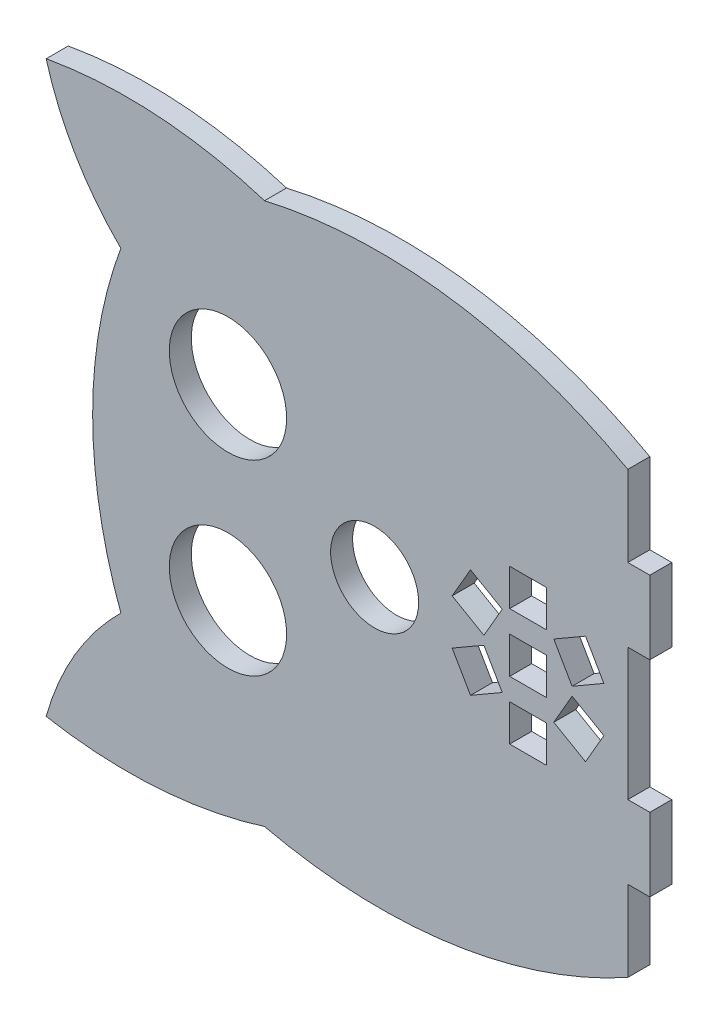
from build123d import *

# Parameters (mm, degrees)
SKETCH2_R           = 8
SKETCH2_R_2         = 6
SKETCH2_W           = 5
SKETCH2_H           = 5
BOSS_EXTRUDE1_DEPTH = 3


with BuildPart() as part:
    # Sketch2 → Boss-Extrude1 (new body)
    with BuildSketch(Plane.XY):
        with BuildLine():
            Line((81.032103119, 50.181312), (81.032103119, 60.181312))
            Line((81.032103119, 60.181312), (78.032103119, 60.181312))
            Line((78.032103119, 60.181312), (78.032103119, 71.181312))
            ThreePointArc((78.032103119, 71.181312), (53.908058205, 79.251221529), (28.494548306, 78.134755037))
            ThreePointArc((28.494548306, 78.134755037), (13.721692274, 80.8793749), (-1.279201176, 80.017163065))
            ThreePointArc((-1.279201176, 80.017163065), (2.677054283, 70.700200378), (8.902417187, 62.718809041))
            ThreePointArc((8.902417187, 62.718809041), (5.05730693, 41.181312), (8.902417187, 19.643814959))
            ThreePointArc((8.902417187, 19.643814959), (2.677054283, 11.662423622), (-1.279201176, 2.345460935))
            ThreePointArc((-1.279201176, 2.345460935), (13.721692274, 1.4832491), (28.494548306, 4.227868963))
            ThreePointArc((28.494548306, 4.227868963), (53.908058205, 3.111402471), (78.032103119, 11.181312))
            Line((78.032103119, 11.181312), (78.032103119, 22.181312))
            Line((78.032103119, 22.181312), (81.032103119, 22.181312))
            Line((81.032103119, 22.181312), (81.032103119, 32.181312))
            Line((81.032103119, 32.181312), (78.032103119, 32.181312))
            Line((78.032103119, 32.181312), (78.032103119, 50.181312))
            Line((78.032103119, 50.181312), (81.032103119, 50.181312))
        make_face()
        with Locations((23.507028058, 53.931312)):
            Circle(SKETCH2_R, mode=Mode.SUBTRACT)
        with Locations((43.507028058, 41.181312)):
            Circle(SKETCH2_R_2, mode=Mode.SUBTRACT)
        with Locations((23.507028058, 28.431312)):
            Circle(SKETCH2_R, mode=Mode.SUBTRACT)
        with Locations((64.423022125, 41.181312)):
            Rectangle(SKETCH2_W, SKETCH2_H, mode=Mode.SUBTRACT)
        with Locations((64.423022125, 33.181312)):
            Rectangle(SKETCH2_W, SKETCH2_H, mode=Mode.SUBTRACT)
        Polygon((72.266288865, 48.59637551), (67.936161846, 46.09637551), (70.436161846, 41.766248491), (74.766288865, 44.266248491), align=None, mode=Mode.SUBTRACT)
        Polygon((67.936161846, 36.266248491), (72.266288865, 33.766248491), (74.766288865, 38.09637551), (70.436161846, 40.596375509), align=None, mode=Mode.SUBTRACT)
        with Locations((64.423022125, 49.181312)):
            Rectangle(SKETCH2_W, SKETCH2_H, mode=Mode.SUBTRACT)
        Polygon((56.579755385, 33.766248491), (60.909882404, 36.266248491), (58.409882404, 40.59637551), (54.079755385, 38.09637551), align=None, mode=Mode.SUBTRACT)
        Polygon((60.909882404, 46.09637551), (56.579755385, 48.596375509), (54.079755385, 44.266248491), (58.409882404, 41.766248491), align=None, mode=Mode.SUBTRACT)
    extrude(amount=BOSS_EXTRUDE1_DEPTH)


solid = part.part
